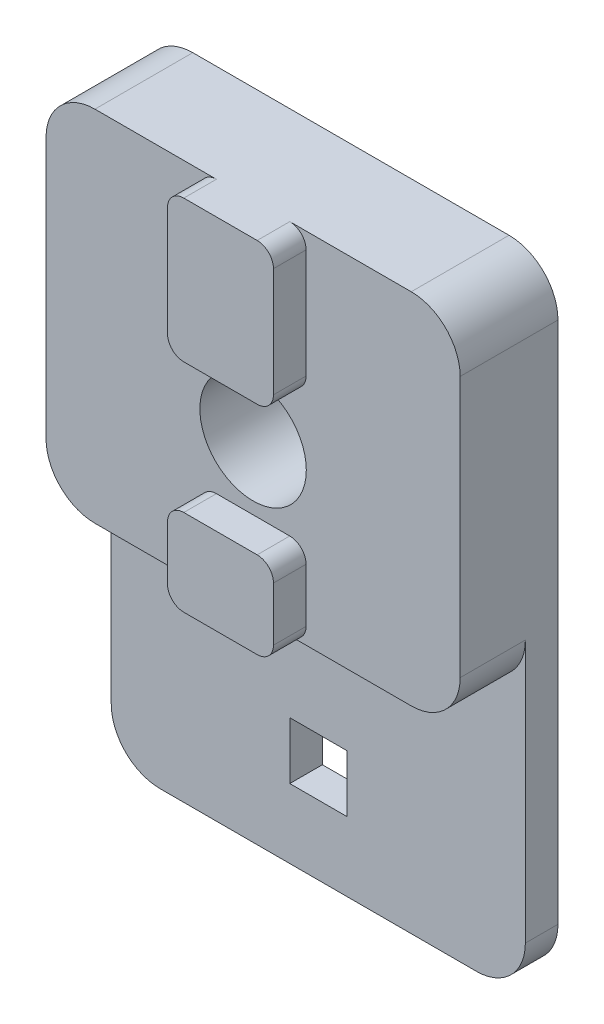
from build123d import *

# Parameters (mm, degrees)
MAIN_FEATURES_SKETCH_W     = 25.4
MAIN_FEATURES_SKETCH_H     = 38.1
MAIN_FEATURES_SKETCH_R     = 3.2639
MAIN_FEATURES_SKETCH_W_2   = 3.5
MAIN_FEATURES_SKETCH_H_2   = 3.5
BASE_DEPTH                 = 2
SKETCH1_3_W                = 25.4
SKETCH1_3_H                = 22
SKETCH1_3_R                = 3.2639
STANDOFF_DEPTH             = 6
PEGS_START                 = 6
MAIN_FEATURES_SKETCH_4_W   = 6.5
MAIN_FEATURES_SKETCH_4_H   = 8.7
MAIN_FEATURES_SKETCH_4_H_2 = 5.3
PEGS_DEPTH                 = 2
FILLET1_R                  = 3
FILLET2_R                  = 1


with BuildPart() as part:
    # main_features_sketch → base (new body)
    with BuildSketch(Plane.XY):
        with Locations((0, 13.05)):
            Rectangle(MAIN_FEATURES_SKETCH_W, MAIN_FEATURES_SKETCH_H)
        with Locations((0, 19.4)):
            Circle(MAIN_FEATURES_SKETCH_R, mode=Mode.SUBTRACT)
        Rectangle(MAIN_FEATURES_SKETCH_W_2, MAIN_FEATURES_SKETCH_H_2, mode=Mode.SUBTRACT)
    extrude(amount=BASE_DEPTH)

    # Sketch1_3 → standoff (add)
    with BuildSketch(Plane.XY):
        with Locations((0, 21.1)):
            Rectangle(SKETCH1_3_W, SKETCH1_3_H)
        with Locations((0, 19.4)):
            Circle(SKETCH1_3_R, mode=Mode.SUBTRACT)
    extrude(amount=STANDOFF_DEPTH)

    # main_features_sketch_4 → pegs (add)
    with BuildSketch(Plane.XY.offset(PEGS_START)):
        with Locations((0, 27.75)):
            Rectangle(MAIN_FEATURES_SKETCH_4_W, MAIN_FEATURES_SKETCH_4_H)
        with Locations((0, 12.75)):
            Rectangle(MAIN_FEATURES_SKETCH_4_W, MAIN_FEATURES_SKETCH_4_H_2)
    extrude(amount=PEGS_DEPTH)

    # Fillet1
    fillet1_edges = [part.edges().sort_by_distance(p)[0] for p in [
        (12.7, -6, 1),
        (-12.7, -6, 1),
        (-12.7, 32.1, 3),
        (12.7, 32.1, 3),
        (12.7, 10.1, 4),
        (-12.7, 10.1, 4),
    ]]
    fillet(fillet1_edges, radius=FILLET1_R)

    # Fillet2
    fillet2_edges = [part.edges().sort_by_distance(p)[0] for p in [
        (3.25, 32.1, 7),
        (-3.25, 32.1, 7),
        (-3.25, 23.4, 7),
        (3.25, 23.4, 7),
        (-3.25, 15.4, 7),
        (-3.25, 10.1, 7),
        (3.25, 10.1, 7),
        (3.25, 15.4, 7),
    ]]
    fillet(fillet2_edges, radius=FILLET2_R)


solid = part.part
